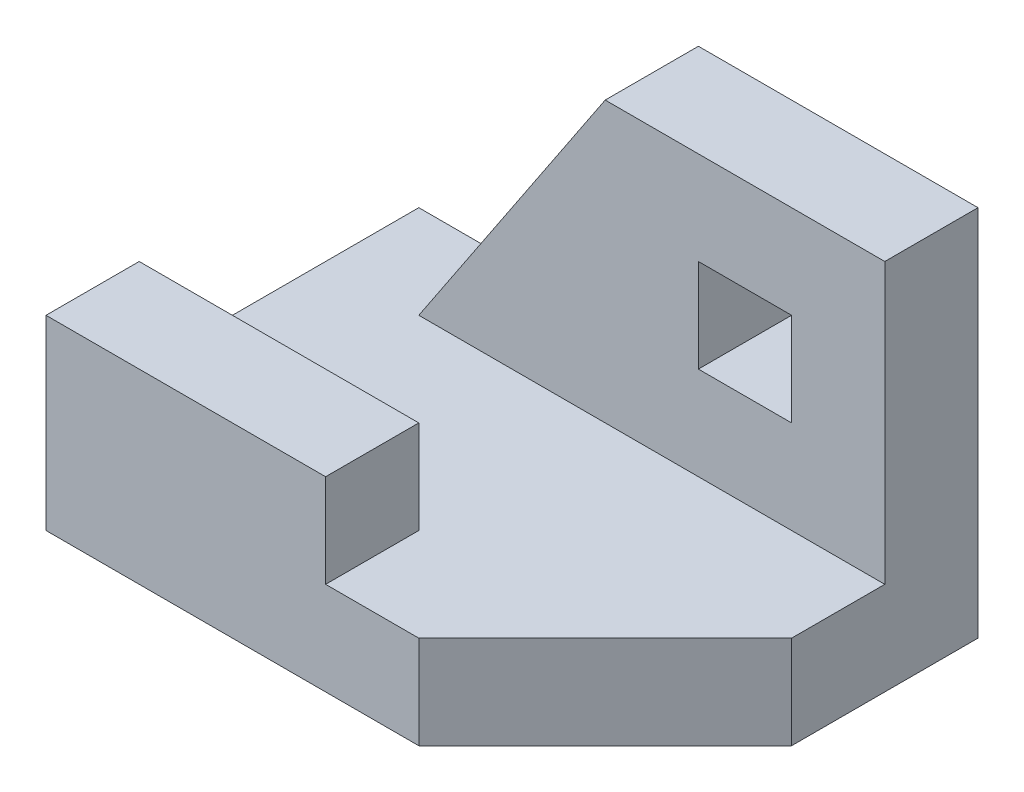
from build123d import *

# Parameters (mm, degrees)
EXTRUDE_1_DEPTH     = 5
SKETCH_1_3_W        = 15
SKETCH_1_3_H        = 5
EXTRUDE_2_DEPTH     = 10
SKETCH_1_4_W        = 25
SKETCH_1_4_H        = 5
EXTRUDE_3_DEPTH     = 20
SKETCH_2_W          = 5
SKETCH_2_H          = 5
CUT_EXTRUDE_1_DEPTH = 20


with BuildPart() as part:
    # 草圖1 → 填料-伸長1 (new body)
    with BuildSketch(Plane(origin=(0, 0, 0), x_dir=(1, 0, 0), z_dir=(0, 1, 0))):
        Polygon((20, 0), (30, 10), (30, 20), (0, 20), (0, 0), align=None)
    extrude(amount=EXTRUDE_1_DEPTH)

    # 草圖1<3> → 填料-伸長2 (add)
    with BuildSketch(Plane(origin=(0, 0, 0), x_dir=(1, 0, 0), z_dir=(0, 1, 0))):
        with Locations((7.5, 2.5)):
            Rectangle(SKETCH_1_3_W, SKETCH_1_3_H)
    extrude(amount=EXTRUDE_2_DEPTH)

    # 草圖1<4> → 填料-伸長3 (add)
    with BuildSketch(Plane(origin=(0, 0, 0), x_dir=(1, 0, 0), z_dir=(0, 1, 0))):
        with Locations((17.5, 17.5)):
            Rectangle(SKETCH_1_4_W, SKETCH_1_4_H)
    extrude(amount=EXTRUDE_3_DEPTH)

    # 草圖2 → 除料-伸長1 (cut)
    with BuildSketch(Plane.XY.offset(-15)):
        with Locations((22.5, 12.5)):
            Rectangle(SKETCH_2_W, SKETCH_2_H)
        Polygon((5, 20), (15, 20), (5, 5), align=None)
    extrude(amount=-CUT_EXTRUDE_1_DEPTH, mode=Mode.SUBTRACT)


solid = part.part
